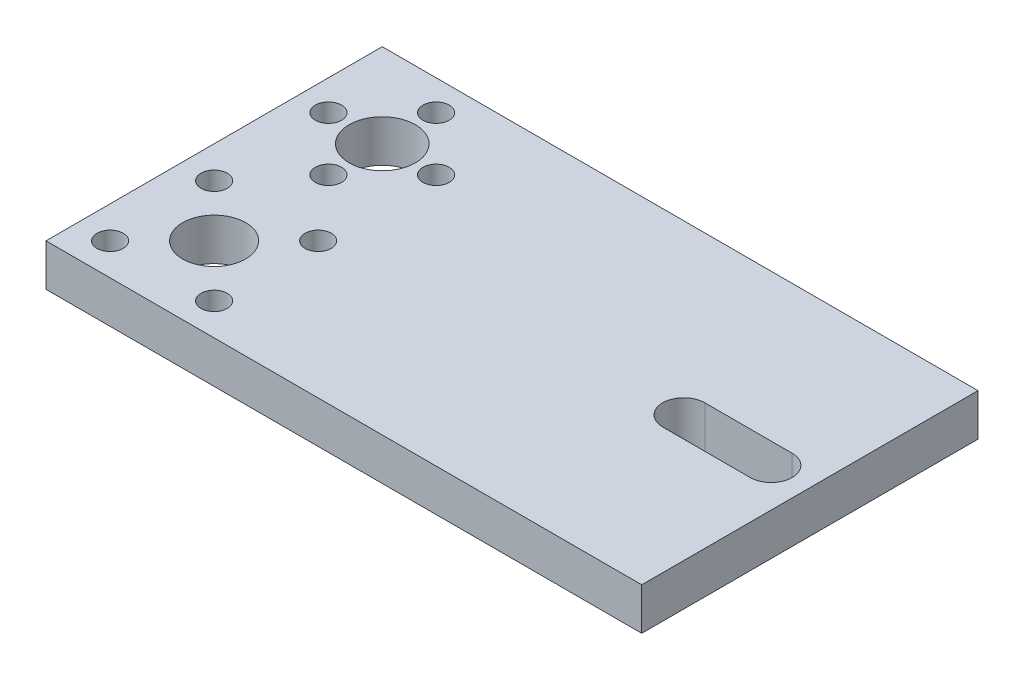
from build123d import *

# Parameters (mm, degrees)
SKETCH1_W           = 90
SKETCH1_H           = 50.8
SKETCH1_R           = 5
SKETCH1_R_2         = 1.984375
SKETCH1_R_3         = 4.7625
BOSS_EXTRUDE1_DEPTH = 6.35


with BuildPart() as part:
    # Sketch1 → Boss-Extrude1 (new body)
    with BuildSketch(Plane(origin=(0, 0, 0), x_dir=(1, 0, 0), z_dir=(0, 1, 0))):
        with Locations((-5, -12.7)):
            Rectangle(SKETCH1_W, SKETCH1_H)
        with Locations((-37.3, 0)):
            Circle(SKETCH1_R, mode=Mode.SUBTRACT)
        with Locations((-37.3, -8.13)):
            Circle(SKETCH1_R_2, mode=Mode.SUBTRACT)
        with Locations((-45.43, 0)):
            Circle(SKETCH1_R_2, mode=Mode.SUBTRACT)
        with Locations((-37.3, 8.13)):
            Circle(SKETCH1_R_2, mode=Mode.SUBTRACT)
        with Locations((-29.17, 0)):
            Circle(SKETCH1_R_2, mode=Mode.SUBTRACT)
        with Locations((-37.3, -25.4)):
            Circle(SKETCH1_R_3, mode=Mode.SUBTRACT)
        with Locations((-45.157724106, -17.542275894)):
            Circle(SKETCH1_R_2, mode=Mode.SUBTRACT)
        with Locations((-29.442275894, -17.542275894)):
            Circle(SKETCH1_R_2, mode=Mode.SUBTRACT)
        with Locations((-29.442275894, -33.257724106)):
            Circle(SKETCH1_R_2, mode=Mode.SUBTRACT)
        with Locations((-45.157724106, -33.257724106)):
            Circle(SKETCH1_R_2, mode=Mode.SUBTRACT)
        with BuildLine():
            Line((20.945, -9.525), (34.155, -9.525))
            ThreePointArc((34.155, -9.525), (37.33, -12.7), (34.155, -15.875))
            Line((34.155, -15.875), (20.945, -15.875))
            ThreePointArc((20.945, -15.875), (17.77, -12.7), (20.945, -9.525))
        make_face(mode=Mode.SUBTRACT)
    extrude(amount=BOSS_EXTRUDE1_DEPTH)


solid = part.part
